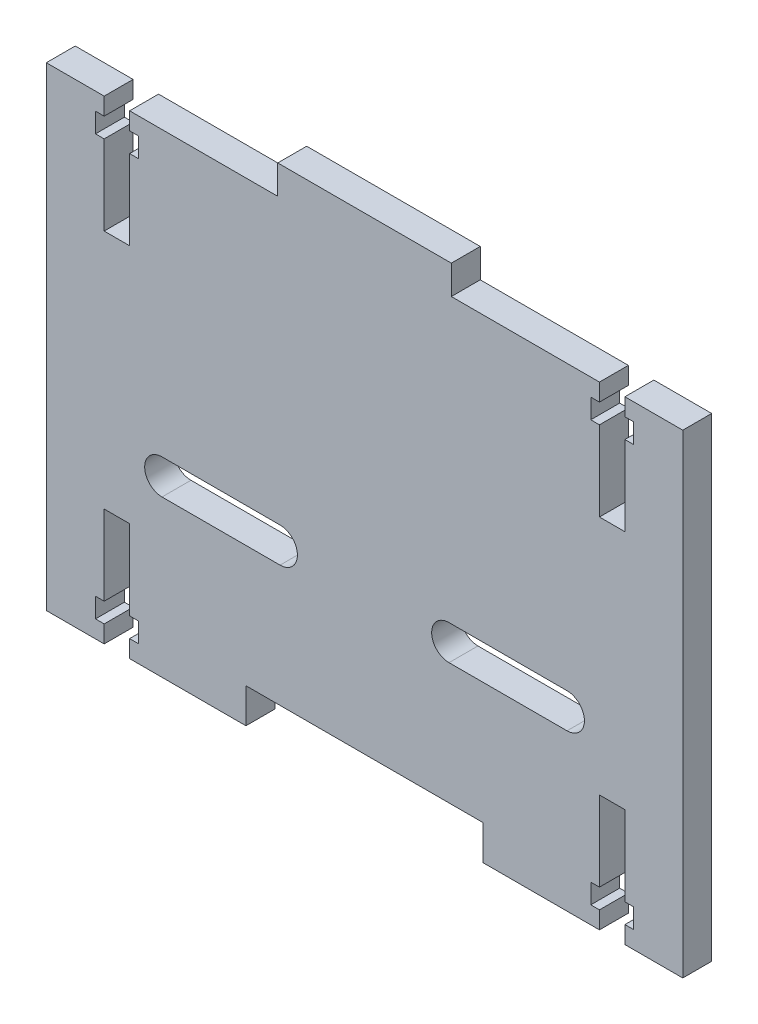
from build123d import *

# Parameters (mm, degrees)
BOSS_EXTRUDE1_DEPTH = 5
CUT_EXTRUDE1_DEPTH  = 5
CUT_EXTRUDE2_DEPTH  = 10


with BuildPart() as part:
    # Sketch1 → Boss-Extrude1 (new body)
    with BuildSketch(Plane.XY):
        Polygon((20.5, -41), (20.5, -35), (-20.5, -35), (-20.5, -41), (-55, -41), (-55, 41), (-15, 41), (-15, 46), (15, 46), (15, 41), (55, 41), (55, -41), align=None)
    extrude(amount=BOSS_EXTRUDE1_DEPTH)

    # Sketch2 → Cut-Extrude1 (cut)
    with BuildSketch(Plane(origin=(0, 0, 0), x_dir=(-1, 0, 0), z_dir=(0, 0, -1))):
        Polygon((-40.6, -38), (-40.6, -41), (-45, -41), (-45, -38), (-46.5, -38), (-46.5, -34.6), (-45, -34.6), (-45, -20.8), (-40.6, -20.8), (-40.6, -34.6), (-39.1, -34.6), (-39.1, -38), align=None)
        Polygon((45, -41), (45, -38), (46.5, -38), (46.5, -34.6), (45, -34.6), (45, -20.8), (40.6, -20.8), (40.6, -34.6), (39.1, -34.6), (39.1, -38), (40.6, -38), (40.6, -41), align=None)
        Polygon((40.6, 38), (40.6, 41), (45, 41), (45, 38), (46.5, 38), (46.5, 34.6), (45, 34.6), (45, 20.8), (40.6, 20.8), (40.6, 34.6), (39.1, 34.6), (39.1, 38), align=None)
        Polygon((-45, 41), (-45, 38), (-46.5, 38), (-46.5, 34.6), (-45, 34.6), (-45, 20.8), (-40.6, 20.8), (-40.6, 34.6), (-39.1, 34.6), (-39.1, 38), (-40.6, 38), (-40.6, 41), align=None)
    extrude(amount=-CUT_EXTRUDE1_DEPTH, mode=Mode.SUBTRACT)

    # Sketch3 → Cut-Extrude2 (cut)
    with BuildSketch(Plane(origin=(0, 0, 0), x_dir=(-1, 0, 0), z_dir=(0, 0, -1))):
        with BuildLine():
            Line((-14.6, -14), (-35, -14))
            ThreePointArc((-35, -14), (-38, -11), (-35, -8))
            Line((-35, -8), (-14.6, -8))
            ThreePointArc((-14.6, -8), (-11.6, -11), (-14.6, -14))
        make_face()
        with BuildLine():
            Line((14.6, -14), (35, -14))
            ThreePointArc((35, -14), (38, -11), (35, -8))
            Line((35, -8), (14.6, -8))
            ThreePointArc((14.6, -8), (11.6, -11), (14.6, -14))
        make_face()
    extrude(amount=-CUT_EXTRUDE2_DEPTH, mode=Mode.SUBTRACT)


solid = part.part
